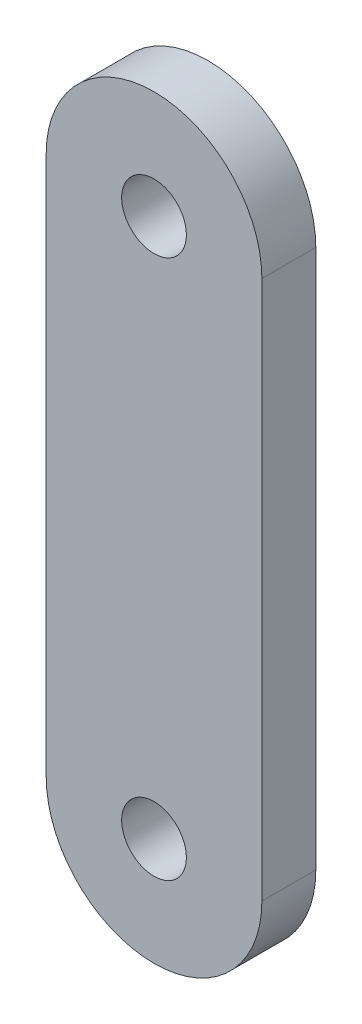
from build123d import *

# Parameters (mm, degrees)
CROQUIS1_R              = 1.5
SALIENTE_EXTRUIR1_DEPTH = 2.5


with BuildPart() as part:
    # Croquis1 → Saliente-Extruir1 (new body)
    with BuildSketch(Plane.XY):
        with BuildLine():
            Line((-5, 25), (-5, 0))
            ThreePointArc((-5, 0), (0, -5), (5, 0))
            Line((5, 0), (5, 25))
            ThreePointArc((5, 25), (0, 30), (-5, 25))
        make_face()
        Circle(CROQUIS1_R, mode=Mode.SUBTRACT)
        with Locations((0, 25)):
            Circle(CROQUIS1_R, mode=Mode.SUBTRACT)
    extrude(amount=SALIENTE_EXTRUIR1_DEPTH)


solid = part.part
